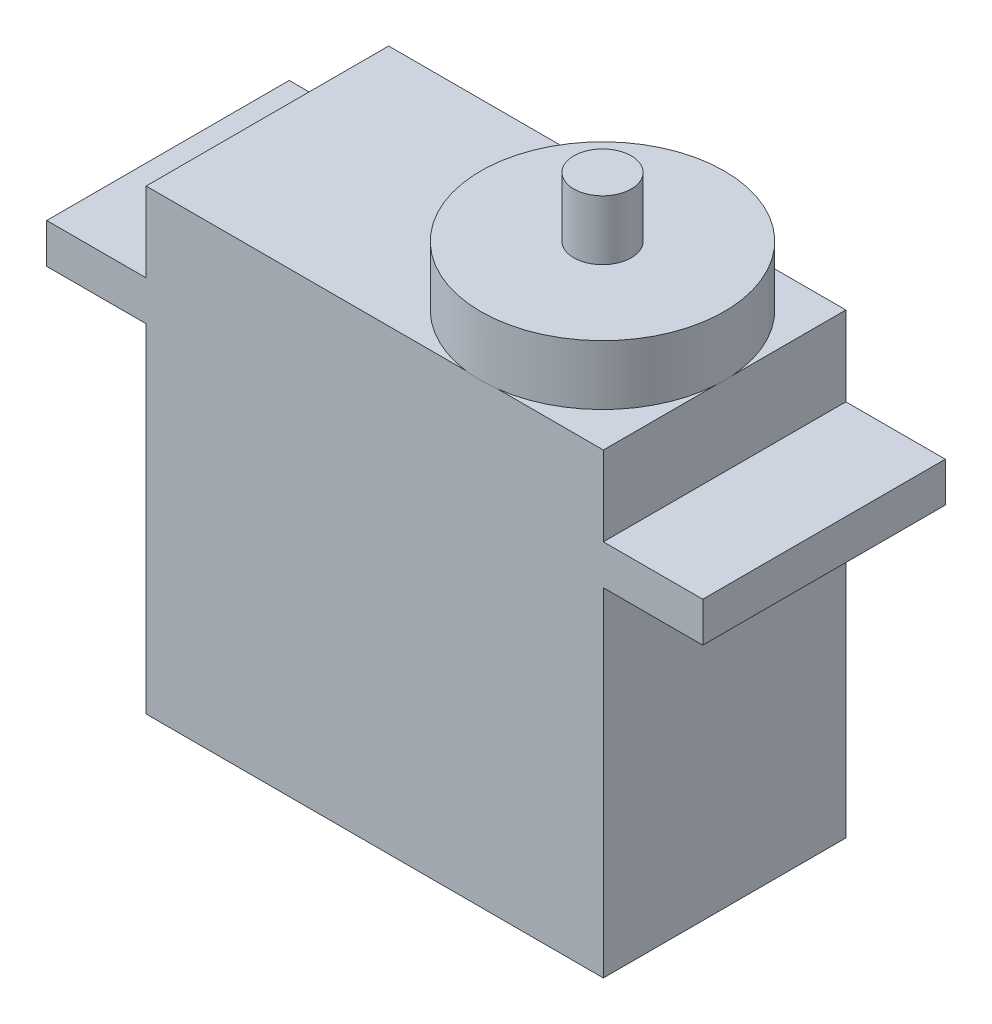
from build123d import *

# Parameters (mm, degrees)
BOSS_EXTRUDE1_DEPTH = 12.2
SKETCH2_R           = 6.126682997
BOSS_EXTRUDE2_DEPTH = 3
SKETCH3_R           = 1.445
BOSS_EXTRUDE3_DEPTH = 3


with BuildPart() as part:
    # Sketch1 → Boss-Extrude1 (new body)
    with BuildSketch(Plane.XY):
        Polygon((0, 0), (23, 0), (23, 17), (28, 17), (28, 19), (23, 19), (23, 23), (0, 23), (0, 19), (-5, 19), (-5, 17), (0, 17), align=None)
    extrude(amount=BOSS_EXTRUDE1_DEPTH)

    # Sketch2 → Boss-Extrude2 (add)
    with BuildSketch(Plane(origin=(0, 23, 0), x_dir=(1, 0, 0), z_dir=(0, 1, 0))):
        with Locations((16.884532498, -6.126394767)):
            Circle(SKETCH2_R)
    extrude(amount=BOSS_EXTRUDE2_DEPTH)

    # Sketch3 → Boss-Extrude3 (add)
    with BuildSketch(Plane(origin=(0, 26, 0), x_dir=(1, 0, 0), z_dir=(0, 1, 0))):
        with Locations((16.884532498, -6.126394767)):
            Circle(SKETCH3_R)
    extrude(amount=BOSS_EXTRUDE3_DEPTH)


solid = part.part
